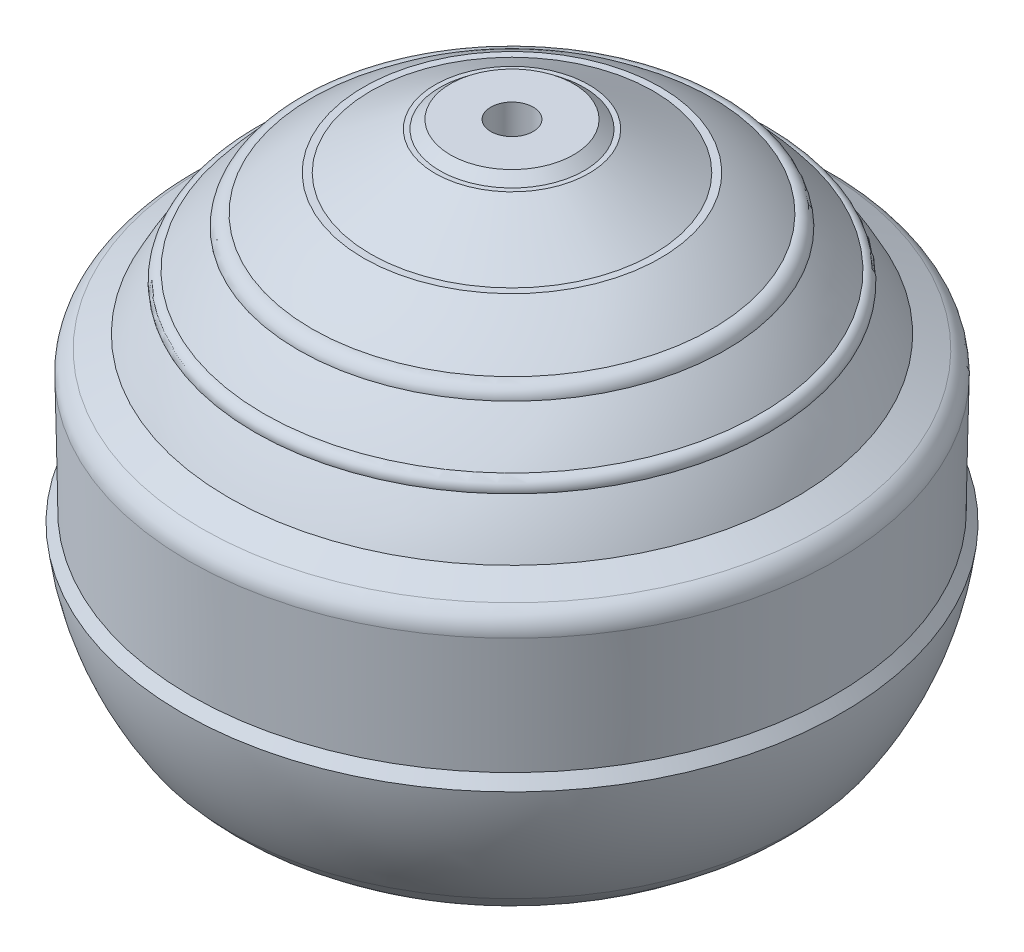
from build123d import *

# Parameters (mm, degrees)
SKETCH2_R          = 0.9
CUT_EXTRUDE1_DEPTH = 10


with BuildPart() as part:
    # Sketch1 → Revolve1 (revolve)
    with BuildSketch(Plane.XY):
        with BuildLine():
            Line((0, 0), (0, -2.033797595))
            Line((0, -2.033797595), (0.9, -2.033797595))
            ThreePointArc((0.9, -2.033797595), (11.039125415, -9.294927197), (9.255545592, -21.637727135))
            Line((9.255545592, -21.637727135), (10.25750189, -21.637727135))
            ThreePointArc((10.25750189, -21.637727135), (11.216781964, -20.984862896), (12.035770488, -20.162848435))
            ThreePointArc((12.035770488, -20.162848435), (13.336250032, -17.622308215), (14, -14.846515061))
            Line((14, -14.846515061), (13.65, -14.381673028))
            Line((13.65, -14.381673028), (13.738757731, -9.380034665))
            ThreePointArc((13.738757731, -9.380034665), (13.592988482, -8.842139112), (13.18196088, -8.465792714))
            Line((13.18196088, -8.465792714), (12.035770488, -7.89935064))
            ThreePointArc((12.035770488, -7.89935064), (11.513052517, -6.958117416), (10.919550231, -6.059836227))
            ThreePointArc((10.919550231, -6.059836227), (10.849987846, -5.720823655), (10.543635929, -5.559836227))
            ThreePointArc((10.543635929, -5.559836227), (9.837206407, -4.731129974), (9.068504463, -3.959836227))
            ThreePointArc((9.068504463, -3.959836227), (8.8868459, -3.592970847), (8.499721613, -3.459836227))
            ThreePointArc((8.499721613, -3.459836227), (7.436594531, -2.657507158), (6.30203453, -1.959836227))
            Line((6.30203453, -1.959836227), (6.00203453, -1.959836227))
            Line((6.00203453, -1.959836227), (3.266196329, -0.359836227))
            Line((3.266196329, -0.359836227), (3.066196329, -0.359836227))
            Line((3.066196329, -0.359836227), (2.616401045, 0))
            Line((2.616401045, 0), (0.9, 0))
            Line((0.9, 0), (0, 0))
        make_face()
    revolve(axis=Axis((0, 0, 0), (0, -1, 0)))

    # Sketch2 → Cut-Extrude1 (cut)
    with BuildSketch(Plane(origin=(0, 0, 0), x_dir=(1, 0, 0), z_dir=(0, 1, 0))):
        Circle(SKETCH2_R)
    extrude(amount=-CUT_EXTRUDE1_DEPTH, mode=Mode.SUBTRACT)


solid = part.part
